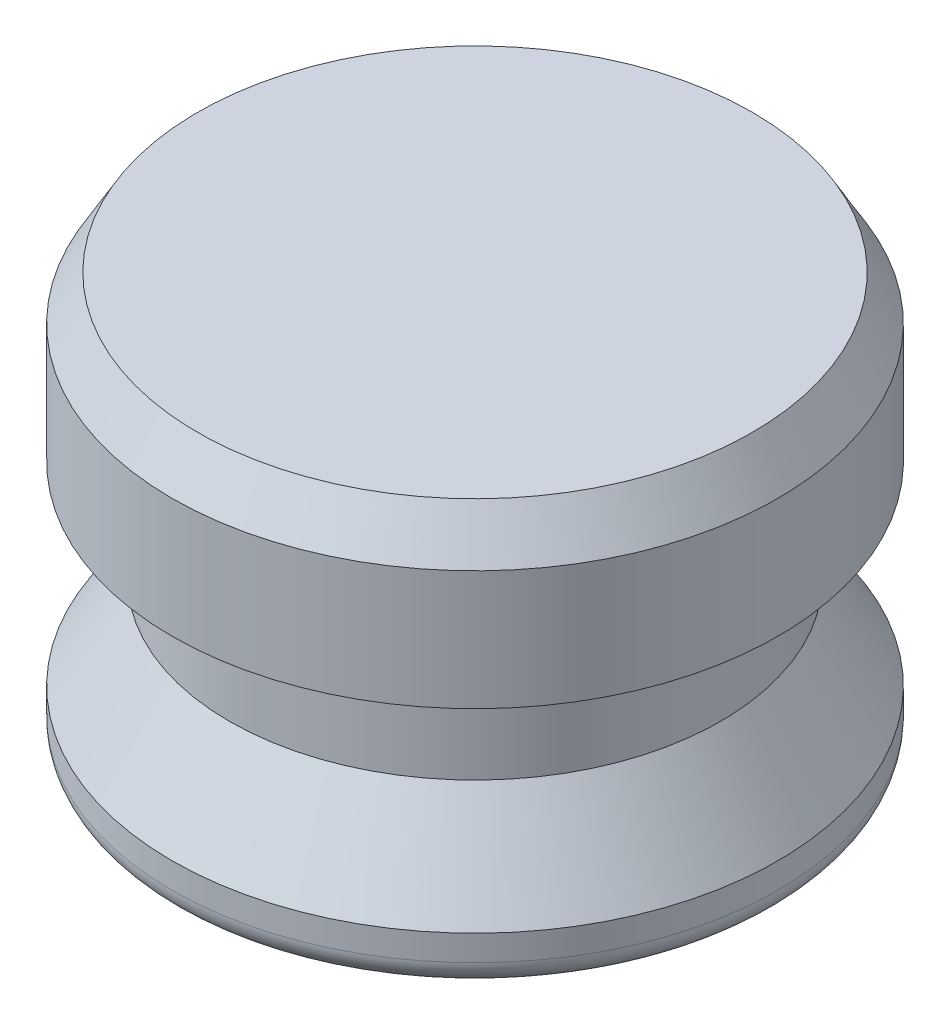
from build123d import *

# Parameters (mm, degrees)
FILLET1_R      = 0.79375
CHAMFER1_SIZE  = 0.79375
CHAMFER1_SIZE2 = 1.374815329


with BuildPart() as part:
    # Sketch1 → Revolve1 (revolve)
    with BuildSketch(Plane.XY):
        Polygon((0, 0), (-9.398, 0), (-9.398, 1.5875), (-7.62, 4.445), (-7.62, 7.62), (-9.398, 7.62), (-9.398, 12.7), (0, 12.7), align=None)
    revolve(axis=Axis((0, 0, 0), (0, 1, 0)))

    # Fillet1
    fillet1_edges = [part.edges().sort_by_distance(p)[0] for p in [
        (9.398, 0, 0),
    ]]
    fillet(fillet1_edges, radius=FILLET1_R)

    # Chamfer1
    chamfer1_edges = [part.edges().sort_by_distance(p)[0] for p in [
        (9.398, 12.7, 0),
    ]]
    chamfer1_side = [part.faces().sort_by_distance(p)[0] for p in [
        (0, 12.7, 0),
    ]]
    chamfer(chamfer1_edges, length=CHAMFER1_SIZE, length2=CHAMFER1_SIZE2, reference=chamfer1_side[0])


solid = part.part
